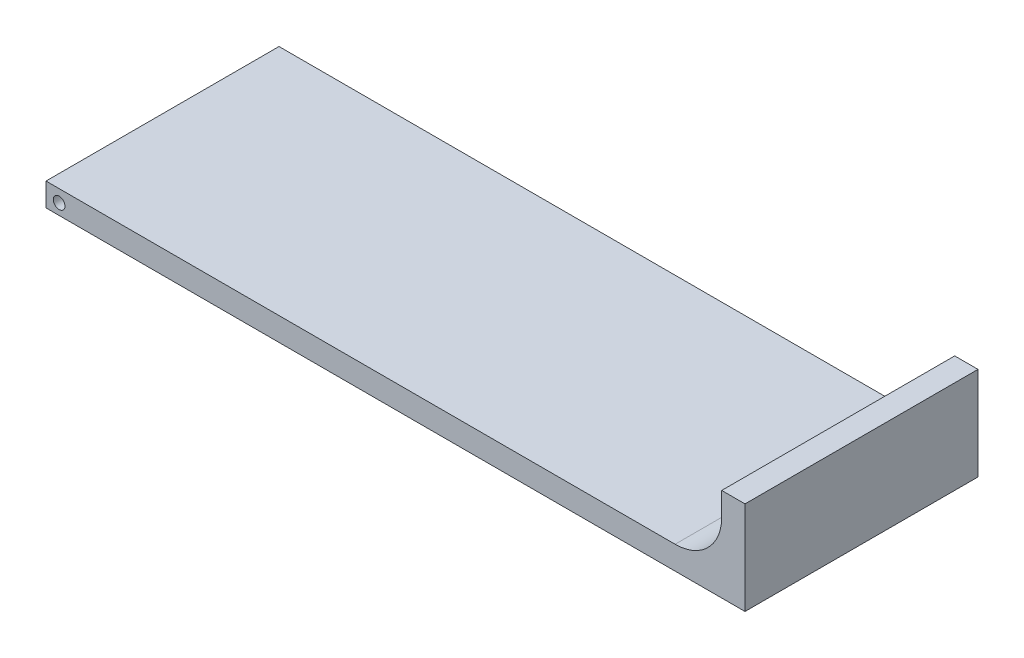
from build123d import *

# Parameters (mm, degrees)
BOSS_EXTRUDE1_DEPTH = 10
FILLET1_R           = 2
SKETCH3_R           = 0.25
CUT_EXTRUDE1_DEPTH  = 11


with BuildPart() as part:
    # Sketch1 → Boss-Extrude1 (new body)
    with BuildSketch(Plane.XY):
        Polygon((4, 3), (5, 3), (5, -1), (-25, -1), (-25, 0), (4, 0), align=None)
    extrude(amount=BOSS_EXTRUDE1_DEPTH)

    # Fillet1
    fillet1_edges = [part.edges().sort_by_distance(p)[0] for p in [
        (4, 0, 5),
    ]]
    fillet(fillet1_edges, radius=FILLET1_R)

    # Sketch3 → Cut-Extrude1 (cut, through all)
    with BuildSketch(Plane.XY.offset(10)):
        with Locations((-24.436460419, -0.529384592)):
            Circle(SKETCH3_R)
    extrude(amount=-CUT_EXTRUDE1_DEPTH, mode=Mode.SUBTRACT)


solid = part.part
